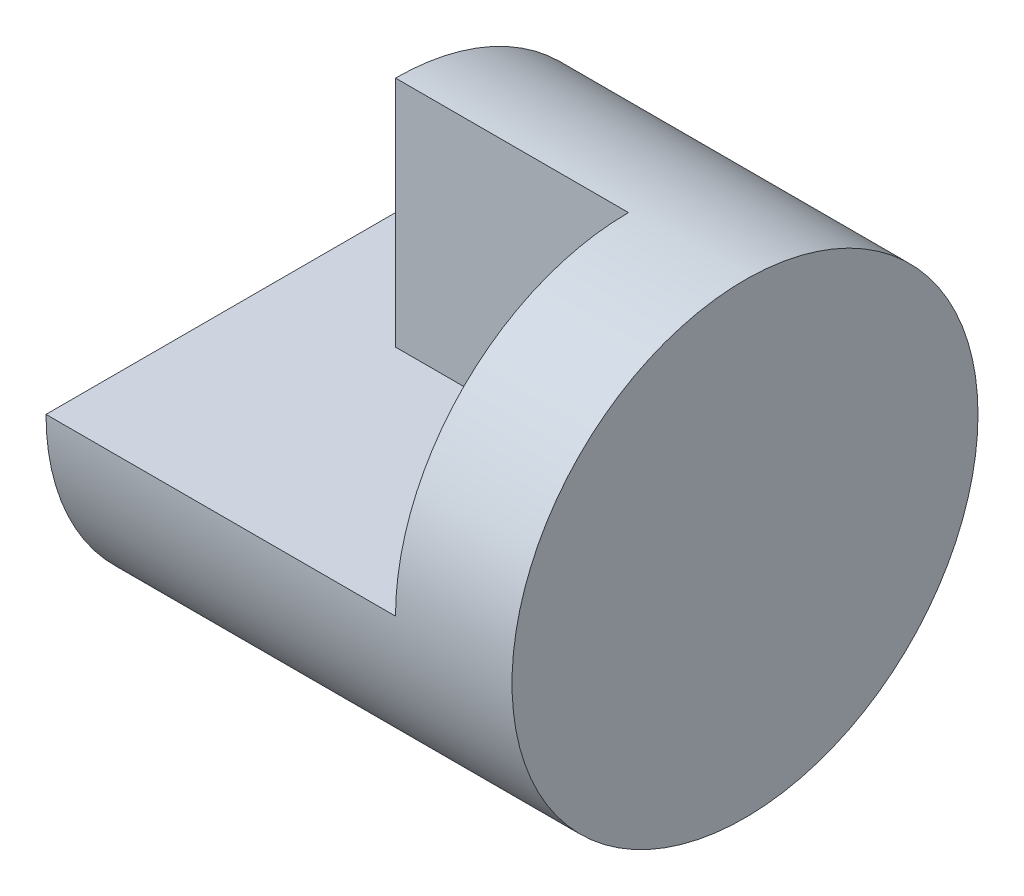
from build123d import *

# Parameters (mm, degrees)
SKETCH1_R           = 2
BOSS_EXTRUDE1_DEPTH = 2
CUT_EXTRUDE1_DEPTH  = 4


with BuildPart() as part:
    # Sketch1 → Boss-Extrude1 (new body, symmetric)
    with BuildSketch(Plane(origin=(0, 0, 0), x_dir=(0, 0, -1), z_dir=(1, 0, 0))):
        Circle(SKETCH1_R)
    extrude(amount=BOSS_EXTRUDE1_DEPTH, both=True)

    # Sketch3 → Cut-Extrude1 (cut)
    with BuildSketch(Plane(origin=(0, 0, 0), x_dir=(1, 0, 0), z_dir=(0, 1, 0))):
        Polygon((-2, 2), (-2, -2), (1, -2), (1, 0), (-1, 0), (-1, 2), align=None)
    extrude(amount=CUT_EXTRUDE1_DEPTH, mode=Mode.SUBTRACT)


solid = part.part
